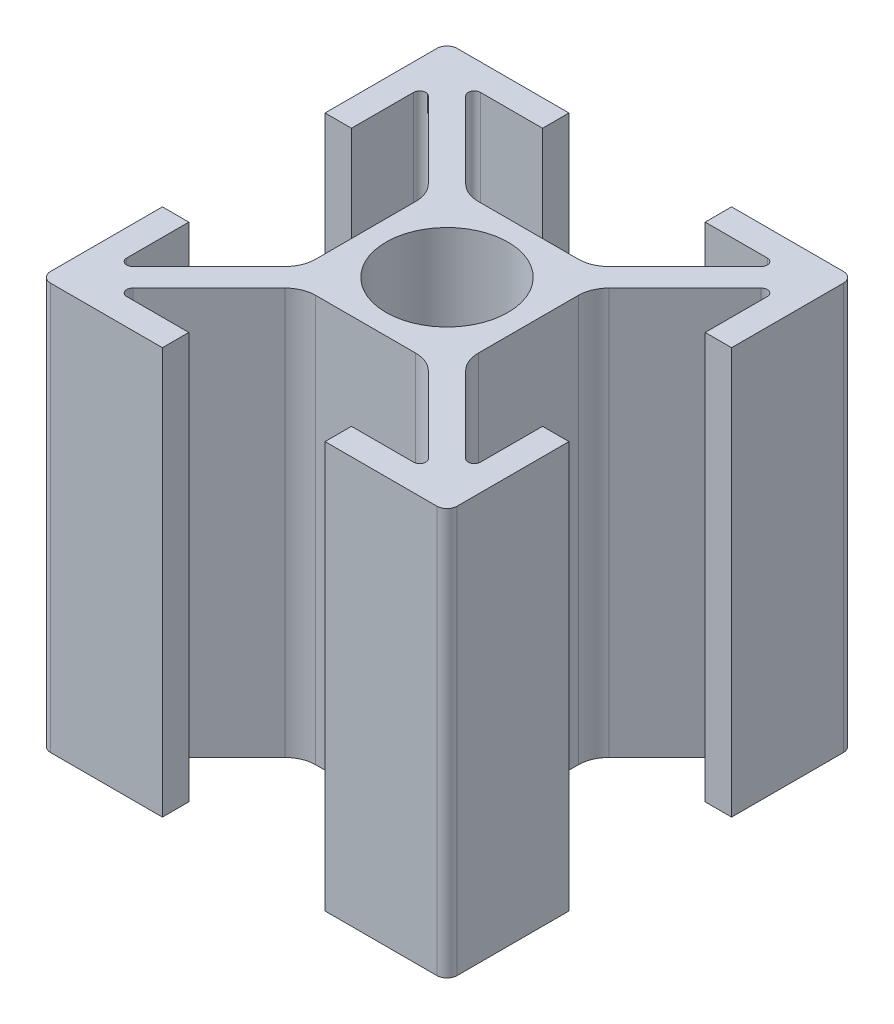
from build123d import *

# Parameters (mm, degrees)
ESBO_O1_R                = 3
RESSALTO_EXTRUS_O1_DEPTH = 20


with BuildPart() as part:
    # Esboço1 → Ressalto-extrusão1 (new body)
    with BuildSketch(Plane(origin=(0, 0, 0), x_dir=(1, 0, 0), z_dir=(0, 1, 0))):
        with BuildLine():
            Line((-7.056497116, 8.7), (-4, 8.7))
            Line((-4, 8.7), (-4, 10))
            Line((-4, 10), (-9.5, 10))
            ThreePointArc((-9.5, 10), (-9.853553391, 9.853553391), (-10, 9.5))
            Line((-10, 9.5), (-10, 4))
            Line((-10, 4), (-8.7, 4))
            Line((-8.7, 4), (-8.7, 7.056497116))
            ThreePointArc((-8.7, 7.056497116), (-8.51480503, 7.333660975), (-8.187867966, 7.26862915))
            Line((-8.187867966, 7.26862915), (-4.439339828, 3.520101013))
            ThreePointArc((-4.439339828, 3.520101013), (-4.114180701, 3.033465989), (-4, 2.459440841))
            Line((-4, 2.459440841), (-4, -2.459440841))
            ThreePointArc((-4, -2.459440841), (-4.114180701, -3.033465989), (-4.439339828, -3.520101013))
            Line((-4.439339828, -3.520101013), (-8.187867966, -7.26862915))
            ThreePointArc((-8.187867966, -7.26862915), (-8.51480503, -7.333660975), (-8.7, -7.056497116))
            Line((-8.7, -7.056497116), (-8.7, -4))
            Line((-8.7, -4), (-10, -4))
            Line((-10, -4), (-10, -9.5))
            ThreePointArc((-10, -9.5), (-9.853553391, -9.853553391), (-9.5, -10))
            Line((-9.5, -10), (-4, -10))
            Line((-4, -10), (-4, -8.7))
            Line((-4, -8.7), (-7.056497116, -8.7))
            ThreePointArc((-7.056497116, -8.7), (-7.333660975, -8.51480503), (-7.26862915, -8.187867966))
            Line((-7.26862915, -8.187867966), (-3.520101013, -4.439339828))
            ThreePointArc((-3.520101013, -4.439339828), (-3.033465989, -4.114180701), (-2.459440841, -4))
            Line((-2.459440841, -4), (2.459440841, -4))
            ThreePointArc((2.459440841, -4), (3.033465989, -4.114180701), (3.520101013, -4.439339828))
            Line((3.520101013, -4.439339828), (7.26862915, -8.187867966))
            ThreePointArc((7.26862915, -8.187867966), (7.333660975, -8.51480503), (7.056497116, -8.7))
            Line((7.056497116, -8.7), (4, -8.7))
            Line((4, -8.7), (4, -10))
            Line((4, -10), (9.5, -10))
            ThreePointArc((9.5, -10), (9.853553391, -9.853553391), (10, -9.5))
            Line((10, -9.5), (10, -4))
            Line((10, -4), (8.7, -4))
            Line((8.7, -4), (8.7, -7.056497116))
            ThreePointArc((8.7, -7.056497116), (8.51480503, -7.333660975), (8.187867966, -7.26862915))
            Line((8.187867966, -7.26862915), (4.439339828, -3.520101013))
            ThreePointArc((4.439339828, -3.520101013), (4.114180701, -3.033465989), (4, -2.459440841))
            Line((4, -2.459440841), (4, 2.459440841))
            ThreePointArc((4, 2.459440841), (4.114180701, 3.033465989), (4.439339828, 3.520101013))
            Line((4.439339828, 3.520101013), (8.187867966, 7.26862915))
            ThreePointArc((8.187867966, 7.26862915), (8.51480503, 7.333660975), (8.7, 7.056497116))
            Line((8.7, 7.056497116), (8.7, 4))
            Line((8.7, 4), (10, 4))
            Line((10, 4), (10, 9.5))
            ThreePointArc((10, 9.5), (9.853553391, 9.853553391), (9.5, 10))
            Line((9.5, 10), (4, 10))
            Line((4, 10), (4, 8.7))
            Line((4, 8.7), (7.056497116, 8.7))
            ThreePointArc((7.056497116, 8.7), (7.333660975, 8.51480503), (7.26862915, 8.187867966))
            Line((7.26862915, 8.187867966), (3.520101013, 4.439339828))
            ThreePointArc((3.520101013, 4.439339828), (3.033465989, 4.114180701), (2.459440841, 4))
            Line((2.459440841, 4), (-2.459440841, 4))
            ThreePointArc((-2.459440841, 4), (-3.033465989, 4.114180701), (-3.520101013, 4.439339828))
            Line((-3.520101013, 4.439339828), (-7.26862915, 8.187867966))
            ThreePointArc((-7.26862915, 8.187867966), (-7.333660975, 8.51480503), (-7.056497116, 8.7))
        make_face()
        Circle(ESBO_O1_R, mode=Mode.SUBTRACT)
    extrude(amount=RESSALTO_EXTRUS_O1_DEPTH)


solid = part.part
